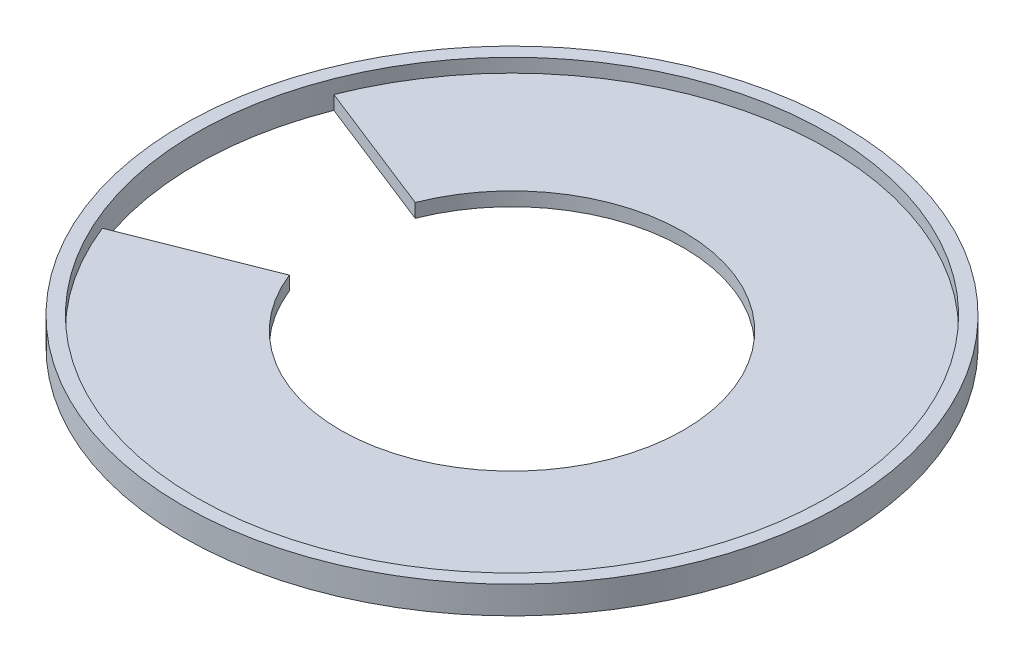
from build123d import *

# Parameters (mm, degrees)
SKETCH1_R           = 48
BOSS_EXTRUDE1_DEPTH = 4
BOSS_EXTRUDE2_DEPTH = 2


with BuildPart() as part:
    # Sketch1 → Boss-Extrude1 (new body)
    with BuildSketch(Plane(origin=(0, 0, 0), x_dir=(1, 0, 0), z_dir=(0, 1, 0))):
        Circle(SKETCH1_R)
        with BuildLine():
            ThreePointArc((46, 0), (8.580105656, -45.192718295), (-42.799208127, -16.859056429))
            ThreePointArc((-42.799208127, -16.859056429), (-46, 0), (-42.799208127, 16.859056429))
            ThreePointArc((-42.799208127, 16.859056429), (8.580105656, 45.192718295), (46, 0))
        make_face(mode=Mode.SUBTRACT)
    extrude(amount=BOSS_EXTRUDE1_DEPTH)

    # Sketch1_3 → Boss-Extrude2 (add)
    with BuildSketch(Plane(origin=(0, 0, 0), x_dir=(1, 0, 0), z_dir=(0, 1, 0))):
        with BuildLine():
            ThreePointArc((25, 0), (4.6631009, -24.561259943), (-23.2604392, -9.162530668))
            Line((-23.2604392, -9.162530668), (-42.799208127, -16.859056429))
            ThreePointArc((-42.799208127, -16.859056429), (8.580105656, -45.192718295), (46, 0))
            ThreePointArc((46, 0), (8.580105656, 45.192718295), (-42.799208127, 16.859056429))
            Line((-42.799208127, 16.859056429), (-23.2604392, 9.162530668))
            ThreePointArc((-23.2604392, 9.162530668), (4.6631009, 24.561259943), (25, 0))
        make_face()
    extrude(amount=BOSS_EXTRUDE2_DEPTH)


solid = part.part
